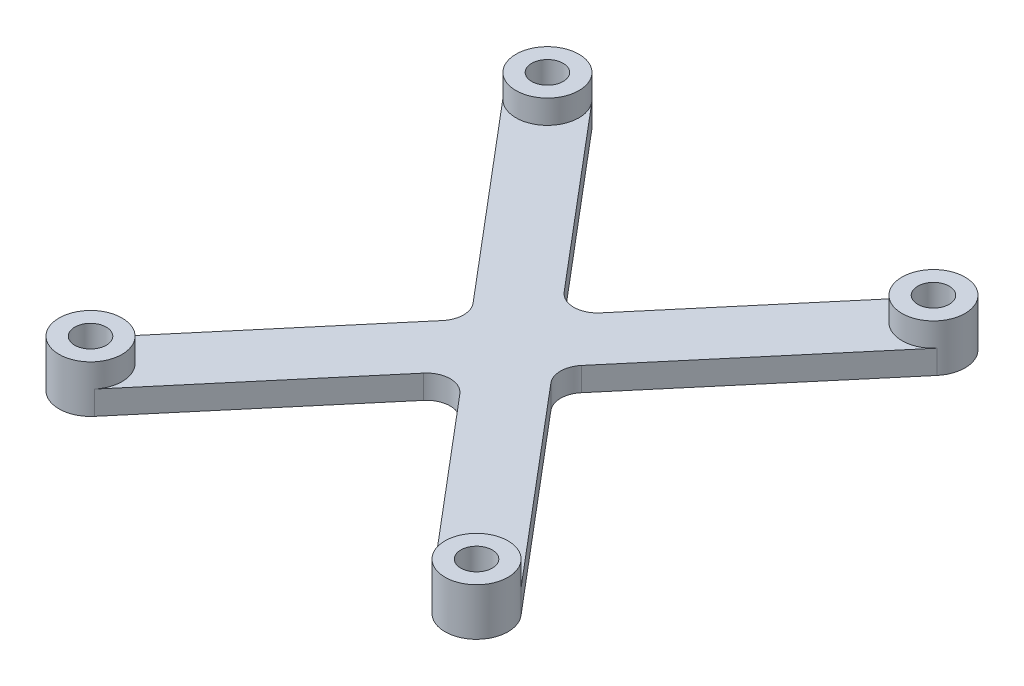
from build123d import *

# Parameters (mm, degrees)
BOSS_EXTRUDE3_DEPTH = 3
FILLET2_R           = 3
SKETCH6_R           = 4
BOSS_EXTRUDE4_DEPTH = 3
SKETCH7_R           = 2
CUT_EXTRUDE4_DEPTH  = 7


with BuildPart() as part:
    # Sketch5 → Boss-Extrude3 (new body)
    with BuildSketch(Plane(origin=(0, 0, 0), x_dir=(1, 0, 0), z_dir=(0, 1, 0))):
        with BuildLine():
            Line((-27.555542502, 26.418593403), (-5.236386006, 0))
            Line((-5.236386006, 0), (0, 6.198171191))
            Line((0, 6.198171191), (-21.444457498, 31.581406597))
            ThreePointArc((-21.444457498, 31.581406597), (-27.081406597, 32.055542502), (-27.555542502, 26.418593403))
        make_face()
        with BuildLine():
            Line((5.236386006, 0), (0, -6.198171191))
            Line((0, -6.198171191), (21.444457498, -31.581406597))
            ThreePointArc((21.444457498, -31.581406597), (27.081406597, -32.055542502), (27.555542502, -26.418593403))
            Line((27.555542502, -26.418593403), (5.236386006, 0))
        make_face()
        with BuildLine():
            Line((21.444457498, 31.581406597), (0, 6.198171191))
            Line((0, 6.198171191), (5.236386006, 0))
            Line((5.236386006, 0), (27.555542502, 26.418593403))
            ThreePointArc((27.555542502, 26.418593403), (27.081406597, 32.055542502), (21.444457498, 31.581406597))
        make_face()
        with BuildLine():
            Line((-5.236386006, 0), (-27.555542502, -26.418593403))
            ThreePointArc((-27.555542502, -26.418593403), (-27.081406597, -32.055542502), (-21.444457498, -31.581406597))
            Line((-21.444457498, -31.581406597), (0, -6.198171191))
            Line((0, -6.198171191), (-5.236386006, 0))
        make_face()
        Polygon((0, 6.198171191), (-5.236386006, 0), (0, -6.198171191), (5.236386006, 0), align=None)
    extrude(amount=BOSS_EXTRUDE3_DEPTH)

    # Fillet2
    fillet2_edges = [part.edges().sort_by_distance(p)[0] for p in [
        (0, 1.5, -6.198171191),
        (5.236386006, 1.5, 0),
        (0, 1.5, 6.198171191),
        (-5.236386006, 1.5, 0),
    ]]
    fillet(fillet2_edges, radius=FILLET2_R)

    # Sketch6 → Boss-Extrude4 (add)
    with BuildSketch(Plane(origin=(0, 3, 0), x_dir=(1, 0, 0), z_dir=(0, 1, 0))):
        with Locations((-24.5, 29)):
            Circle(SKETCH6_R)
        with Locations((24.5, 29)):
            Circle(SKETCH6_R)
        with Locations((-24.5, -29)):
            Circle(SKETCH6_R)
        with Locations((24.5, -29)):
            Circle(SKETCH6_R)
    extrude(amount=BOSS_EXTRUDE4_DEPTH)

    # Sketch7 → Cut-Extrude4 (cut, through all)
    with BuildSketch(Plane(origin=(0, 6, 0), x_dir=(1, 0, 0), z_dir=(0, 1, 0))):
        with Locations((-24.5, -29)):
            Circle(SKETCH7_R)
        with Locations((-24.5, 29)):
            Circle(SKETCH7_R)
        with Locations((24.5, 29)):
            Circle(SKETCH7_R)
        with Locations((24.5, -29)):
            Circle(SKETCH7_R)
    extrude(amount=-CUT_EXTRUDE4_DEPTH, mode=Mode.SUBTRACT)


solid = part.part
